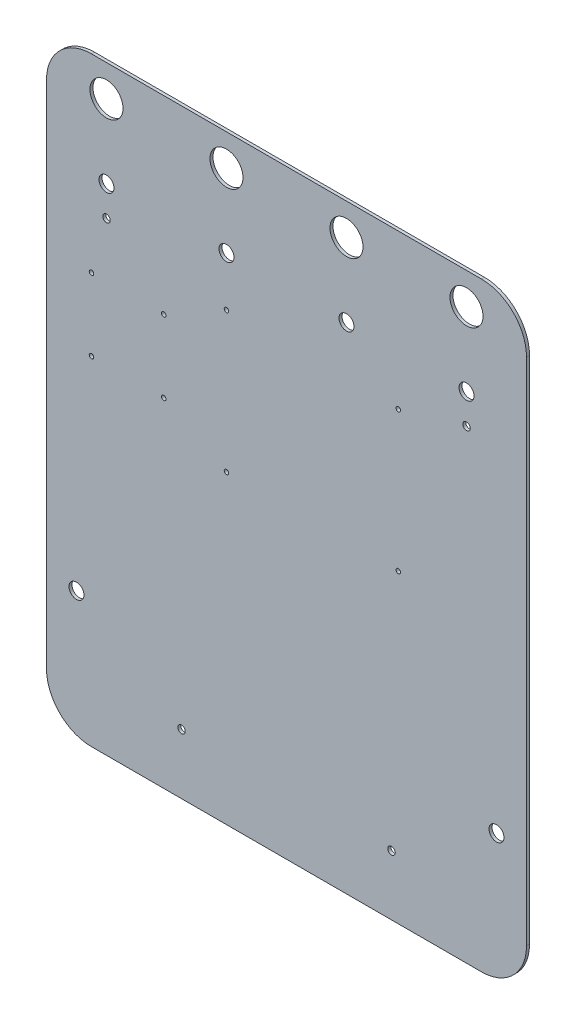
from build123d import *

# Parameters (mm, degrees)
SKETCH_1_R      = 2.5
SKETCH_1_R_2    = 11
SKETCH_1_R_3    = 5
SKETCH_1_R_4    = 1.5
EXTRUDE_1_DEPTH = 2


with BuildPart() as part:
    # 草图1 → 凸台-拉伸1 (new body)
    with BuildSketch(Plane.XY):
        with BuildLine():
            Line((-200.597014925, 350), (59.402985075, 350))
            ThreePointArc((59.402985075, 350), (80.61618851, 341.213203436), (89.402985075, 320))
            Line((89.402985075, 320), (89.402985075, -20))
            ThreePointArc((89.402985075, -20), (80.61618851, -41.213203436), (59.402985075, -50))
            Line((59.402985075, -50), (-200.597014925, -50))
            ThreePointArc((-200.597014925, -50), (-221.810218361, -41.213203436), (-230.597014925, -20))
            Line((-230.597014925, -20), (-230.597014925, 320))
            ThreePointArc((-230.597014925, 320), (-221.810218361, 341.213203436), (-200.597014925, 350))
        make_face()
        with Locations((-190.594777504, 260.002592391)):
            Circle(SKETCH_1_R, mode=Mode.SUBTRACT)
        with Locations((49.405222496, 260.002592391)):
            Circle(SKETCH_1_R, mode=Mode.SUBTRACT)
        with Locations((-140.594777504, -9.997407609)):
            Circle(SKETCH_1_R, mode=Mode.SUBTRACT)
        with Locations((-0.594777504, -9.997407609)):
            Circle(SKETCH_1_R, mode=Mode.SUBTRACT)
        with Locations((-110.597014925, 329)):
            Circle(SKETCH_1_R_2, mode=Mode.SUBTRACT)
        with Locations((-30.597014925, 329)):
            Circle(SKETCH_1_R_2, mode=Mode.SUBTRACT)
        with Locations((-190.597014925, 329)):
            Circle(SKETCH_1_R_2, mode=Mode.SUBTRACT)
        with Locations((49.402985075, 329)):
            Circle(SKETCH_1_R_2, mode=Mode.SUBTRACT)
        with Locations((-210.597014925, 35)):
            Circle(SKETCH_1_R_3, mode=Mode.SUBTRACT)
        with Locations((69.402985075, 35)):
            Circle(SKETCH_1_R_3, mode=Mode.SUBTRACT)
        with Locations((-110.599294274, 247.104711047)):
            Circle(SKETCH_1_R_4, mode=Mode.SUBTRACT)
        with Locations((-110.599294274, 153.604711047)):
            Circle(SKETCH_1_R_4, mode=Mode.SUBTRACT)
        with Locations((3.900705726, 153.604711047)):
            Circle(SKETCH_1_R_4, mode=Mode.SUBTRACT)
        with Locations((3.900705726, 247.104711047)):
            Circle(SKETCH_1_R_4, mode=Mode.SUBTRACT)
        with Locations((-200.598097779, 223.669448039)):
            Circle(SKETCH_1_R_4, mode=Mode.SUBTRACT)
        with Locations((-152.398097779, 223.669448039)):
            Circle(SKETCH_1_R_4, mode=Mode.SUBTRACT)
        with Locations((-200.598097779, 175.469448039)):
            Circle(SKETCH_1_R_4, mode=Mode.SUBTRACT)
        with Locations((-152.398097779, 175.469448039)):
            Circle(SKETCH_1_R_4, mode=Mode.SUBTRACT)
        with Locations((-30.597014925, 280)):
            Circle(SKETCH_1_R_3, mode=Mode.SUBTRACT)
        with Locations((-190.594777504, 280)):
            Circle(SKETCH_1_R_3, mode=Mode.SUBTRACT)
        with Locations((-110.599294274, 280)):
            Circle(SKETCH_1_R_3, mode=Mode.SUBTRACT)
        with Locations((49.405222496, 280)):
            Circle(SKETCH_1_R_3, mode=Mode.SUBTRACT)
    extrude(amount=EXTRUDE_1_DEPTH)


solid = part.part
